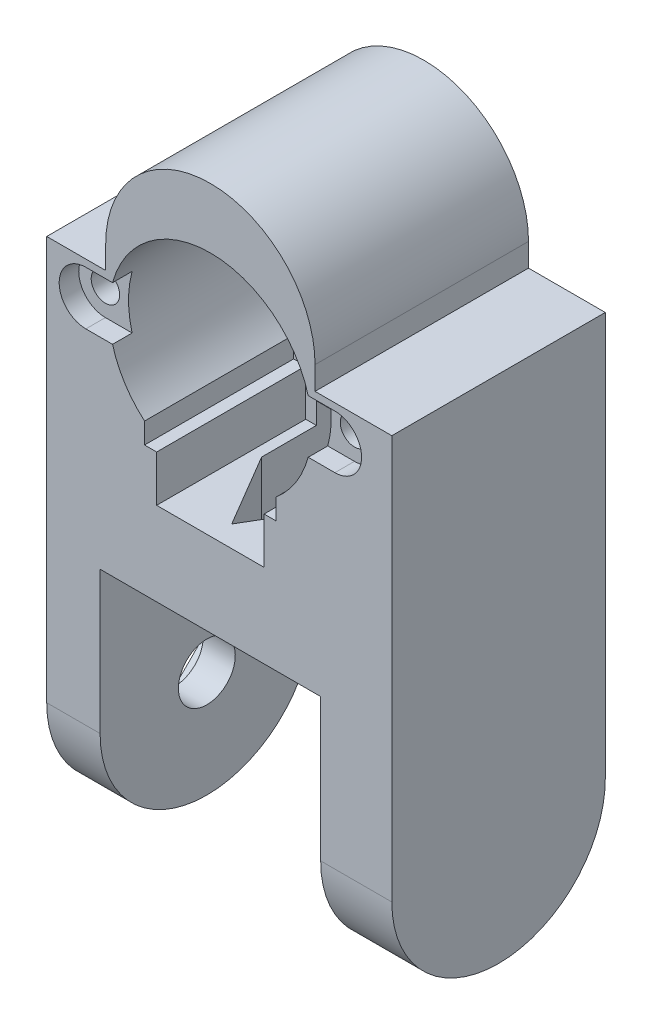
from build123d import *

# Parameters (mm, degrees)
BOSS_EXTRUDE1_DEPTH     = 20.95
BOSS_EXTRUDE2_DEPTH     = 9.05
SKETCH6_R               = 2
CUT_EXTRUDE2_DEPTH      = 10
CUT_EXTRUDE3_DEPTH      = 2.75
SKETCH8_W               = 8.290514233
SKETCH8_H               = 3.25
CUT_EXTRUDE4_DEPTH      = 1
CUT_EXTRUDE4_DEPTH_BACK = 31
SKETCH11_R              = 11.15
BEARING_HOLE_DEPTH      = 7.3
SKETCH9_W               = 12.1
SKETCH9_H               = 21.5
WIRE_HOLE_DEPTH         = 15.75
SKETCH12_W              = 46
SKETCH12_H              = 30
BOSS_EXTRUDE3_DEPTH     = 0.0001
BOSS_EXTRUDE4_DEPTH     = 7.5
BOSS_EXTRUDE5_DEPTH     = 7.5
BOSS_EXTRUDE9_DEPTH     = 2.5
SKETCH15_R              = 4
CUT_EXTRUDE5_DEPTH      = 49.5
SKETCH17_R              = 6.169612062
BOSS_EXTRUDE6_DEPTH     = 10
SKETCH18_R              = 3.85
BOSS_EXTRUDE7_DEPTH     = 14
SKETCH19_R              = 4.675
CUT_EXTRUDE6_DEPTH      = 2
SKETCH24_R              = 3.5
CUT_EXTRUDE7_DEPTH      = 23.7
FILLET1_R               = 0.5
SKETCH25_W              = 8.843315878
SKETCH25_H              = 4.834346013
BOSS_EXTRUDE10_DEPTH    = 2
SKETCH27_W              = 12.1
SKETCH27_H              = 21.5
CUT_EXTRUDE8_DEPTH      = 50.7501
BOSS_EXTRUDE11_DEPTH    = 14.7501
SKETCH29_W              = 15.1
SKETCH29_H              = 3
CUT_EXTRUDE9_DEPTH      = 20.95
SKETCH30_R              = 4
CUT_EXTRUDE10_DEPTH     = 14
CUT_EXTRUDE11_DEPTH     = 3


with BuildPart() as part:
    # Sketch2 → Boss-Extrude1 (new body)
    with BuildSketch(Plane.XY):
        with BuildLine():
            Line((-14.709485767, 40), (-23, 40))
            Line((-23, 40), (-23, 0))
            Line((-23, 0), (23, 0))
            Line((23, 0), (23, 40))
            Line((23, 40), (14.709485767, 40))
            ThreePointArc((14.709485767, 40), (0, 54.709485767), (-14.709485767, 40))
        make_face()
        with BuildLine():
            Line((-7.55, 18.241114036), (-7.55, 14.75))
            Line((-7.55, 14.75), (7.55, 14.75))
            Line((7.55, 14.75), (7.55, 18.241114036))
            Line((7.55, 18.241114036), (9.25, 18.241114036))
            Line((9.25, 18.241114036), (9.25, 21.160258306))
            ThreePointArc((9.25, 21.160258306), (0, 46.25), (-9.25, 21.160258306))
            Line((-9.25, 21.160258306), (-9.25, 18.241114036))
            Line((-9.25, 18.241114036), (-7.55, 18.241114036))
        make_face(mode=Mode.SUBTRACT)
    extrude(amount=BOSS_EXTRUDE1_DEPTH)

    # Sketch3 → Boss-Extrude2 (add)
    with BuildSketch(Plane.XY):
        with BuildLine():
            Line((-14.709485767, 40), (-23, 40))
            Line((-23, 40), (-23, 0))
            Line((-23, 0), (23, 0))
            Line((23, 0), (23, 40))
            Line((23, 40), (14.709485767, 40))
            ThreePointArc((14.709485767, 40), (0, 54.709485767), (-14.709485767, 40))
        make_face()
    extrude(amount=-BOSS_EXTRUDE2_DEPTH)

    # Sketch6 → Cut-Extrude2 (cut)
    with BuildSketch(Plane.XY.offset(20.95)):
        with Locations((-17.5, 32)):
            Circle(SKETCH6_R)
        with Locations((17.5, 32)):
            Circle(SKETCH6_R)
    extrude(amount=-CUT_EXTRUDE2_DEPTH, mode=Mode.SUBTRACT)

    # Sketch7 → Cut-Extrude3 (cut)
    with BuildSketch(Plane.XY.offset(20.95)):
        with BuildLine():
            Line((-17.5, 35.75), (17.5, 35.75))
            ThreePointArc((17.5, 35.75), (21.25, 32), (17.5, 28.25))
            Line((17.5, 28.25), (-17.5, 28.25))
            ThreePointArc((-17.5, 28.25), (-21.25, 32), (-17.5, 35.75))
        make_face()
    extrude(amount=-CUT_EXTRUDE3_DEPTH, mode=Mode.SUBTRACT)

    # Sketch8 → Cut-Extrude4 (cut, two sides)
    with BuildSketch(Plane.XY.offset(20.95)) as cut_extrude4_sk:
        with Locations((-18.854742884, 38.375)):
            Rectangle(SKETCH8_W, SKETCH8_H)
        with Locations((18.854742884, 38.375)):
            Rectangle(SKETCH8_W, SKETCH8_H)
    extrude(amount=CUT_EXTRUDE4_DEPTH, mode=Mode.SUBTRACT)
    extrude(cut_extrude4_sk.sketch, amount=-CUT_EXTRUDE4_DEPTH_BACK, mode=Mode.SUBTRACT)

    # Sketch11 → Bearing Hole (cut)
    with BuildSketch(Plane(origin=(0, 0, -9.05), x_dir=(-1, 0, 0), z_dir=(0, 0, -1))):
        with Locations((0, 40)):
            Circle(SKETCH11_R)
    extrude(amount=-BEARING_HOLE_DEPTH, mode=Mode.SUBTRACT)

    # Sketch9 → Wire Hole (cut, through all)
    with BuildSketch(Plane(origin=(0, 14.75, -19.25), x_dir=(-1, 0, 0), z_dir=(0, 1, 0))):
        with Locations((0, 26.95)):
            Rectangle(SKETCH9_W, SKETCH9_H)
    extrude(amount=-WIRE_HOLE_DEPTH, mode=Mode.SUBTRACT)

    # Sketch12 → Boss-Extrude3 (add)
    with BuildSketch(Plane.XZ):
        with Locations((0, 5.95)):
            Rectangle(SKETCH12_W, SKETCH12_H)
    extrude(amount=BOSS_EXTRUDE3_DEPTH)

    # Sketch13 → Boss-Extrude4 (add)
    with BuildSketch(Plane(origin=(23, 0, 0), x_dir=(0, 0, -1), z_dir=(1, 0, 0))):
        with BuildLine():
            Line((-20.95, -0.0001), (-20.95, -20.0001))
            ThreePointArc((-20.95, -20.0001), (-5.95, -35.0001), (9.05, -20.0001))
            Line((9.05, -20.0001), (9.05, -0.0001))
            Line((9.05, -0.0001), (-20.95, -0.0001))
        make_face()
    extrude(amount=-BOSS_EXTRUDE4_DEPTH)

    # Sketch14 → Boss-Extrude5 (add)
    with BuildSketch(Plane.ZY.offset(23)):
        with BuildLine():
            Line((-9.05, -20.0001), (-9.05, -0.0001))
            Line((-9.05, -0.0001), (20.95, -0.0001))
            Line((20.95, -0.0001), (20.95, -20.0001))
            ThreePointArc((20.95, -20.0001), (5.95, -35.0001), (-9.05, -20.0001))
        make_face()
    extrude(amount=-BOSS_EXTRUDE5_DEPTH)

    # Sketch21 → Boss-Extrude9 (add)
    with BuildSketch(Plane(origin=(23, 0, 0), x_dir=(0, 0, -1), z_dir=(1, 0, 0))):
        with BuildLine():
            Line((-20.95, -20.0001), (-20.95, 36.75))
            Line((-20.95, 36.75), (9.05, 36.75))
            Line((9.05, 36.75), (9.05, -20.0001))
            ThreePointArc((9.05, -20.0001), (-5.95, -35.0001), (-20.95, -20.0001))
        make_face()
    extrude(amount=BOSS_EXTRUDE9_DEPTH)

    # Sketch15 → Cut-Extrude5 (cut, through all)
    with BuildSketch(Plane.ZY.offset(23)):
        with Locations((5.95, -20.0001)):
            Circle(SKETCH15_R)
    extrude(amount=-CUT_EXTRUDE5_DEPTH, mode=Mode.SUBTRACT)

    # Sketch17 → Boss-Extrude6 (add)
    with BuildSketch(Plane(origin=(25.5, 0, -23), x_dir=(0, 0, 1), z_dir=(-1, 0, 0))):
        with Locations((28.95, -20.0001)):
            Circle(SKETCH17_R)
        with BuildLine():
            Line((26.765394773, -18.5001), (31.134605227, -18.5001))
            ThreePointArc((31.134605227, -18.5001), (31.6, -20.0001), (31.134605227, -21.5001))
            Line((31.134605227, -21.5001), (26.765394773, -21.5001))
            ThreePointArc((26.765394773, -21.5001), (26.3, -20.0001), (26.765394773, -18.5001))
        make_face(mode=Mode.SUBTRACT)
    extrude(amount=BOSS_EXTRUDE6_DEPTH)

    # Sketch19 → Cut-Extrude6 (cut)
    with BuildSketch(Plane.ZY.offset(-15.5)):
        with Locations((5.95, -20.0001)):
            Circle(SKETCH19_R)
    extrude(amount=-CUT_EXTRUDE6_DEPTH, mode=Mode.SUBTRACT)

    # Sketch24 → Cut-Extrude7 (cut, through all)
    with BuildSketch(Plane(origin=(0, 0, -1.75), x_dir=(-1, 0, 0), z_dir=(0, 0, -1))):
        with Locations((0, 40)):
            Circle(SKETCH24_R)
    extrude(amount=-CUT_EXTRUDE7_DEPTH, mode=Mode.SUBTRACT)

    # Fillet1
    fillet1_edges = [part.edges().sort_by_distance(p)[0] for p in [
        (11.15, 40, -9.05),
    ]]
    fillet(fillet1_edges, radius=FILLET1_R)

    # Sketch25 → Boss-Extrude10 (add)
    with BuildSketch(Plane(origin=(25.5, 0, 0), x_dir=(0, 0, -1), z_dir=(1, 0, 0))):
        with Locations((-6.185865257, -20.38943492)):
            Rectangle(SKETCH25_W, SKETCH25_H)
    extrude(amount=-BOSS_EXTRUDE10_DEPTH)

    # Sketch27 → Cut-Extrude8 (cut, through all)
    with BuildSketch(Plane(origin=(0, 14.75, 0), x_dir=(1, 0, 0), z_dir=(0, 1, 0))):
        with Locations((0, -7.7)):
            Rectangle(SKETCH27_W, SKETCH27_H)
    extrude(amount=-CUT_EXTRUDE8_DEPTH, mode=Mode.SUBTRACT)

    # Sketch28 → Boss-Extrude11 (add)
    with BuildSketch(Plane.XZ.offset(0.0001)):
        Polygon((-6.05, 7.7), (0, 17.95), (6.05, 7.7), (6.05, 18.45), (-6.05, 18.45), align=None)
    extrude(amount=-BOSS_EXTRUDE11_DEPTH)

    # Sketch29 → Cut-Extrude9 (cut)
    with BuildSketch(Plane.XY.offset(20.95)):
        with Locations((0, 13.25)):
            Rectangle(SKETCH29_W, SKETCH29_H)
    extrude(amount=-CUT_EXTRUDE9_DEPTH, mode=Mode.SUBTRACT)

    # Sketch31 → Cut-Extrude11 (cut)
    with BuildSketch(Plane.ZY.offset(23)):
        Polygon((5.95, -10.0001), (15.95, -20.0001), (5.95, -30.0001), (-4.05, -20.0001), align=None)
    extrude(amount=-CUT_EXTRUDE11_DEPTH, mode=Mode.SUBTRACT)


with BuildPart() as body_2:
    # Sketch18 → Boss-Extrude7 (new body)
    with BuildSketch(Plane.ZY.offset(23)):
        with Locations((5.95, -20.0001)):
            Circle(SKETCH18_R)
    extrude(amount=-BOSS_EXTRUDE7_DEPTH)

    # Sketch30 → Cut-Extrude10 (cut)
    with BuildSketch(Plane.ZY.offset(23)):
        with Locations((5.95, -20.0001)):
            Circle(SKETCH30_R)
    extrude(amount=-CUT_EXTRUDE10_DEPTH, mode=Mode.SUBTRACT)


solid = part.part
